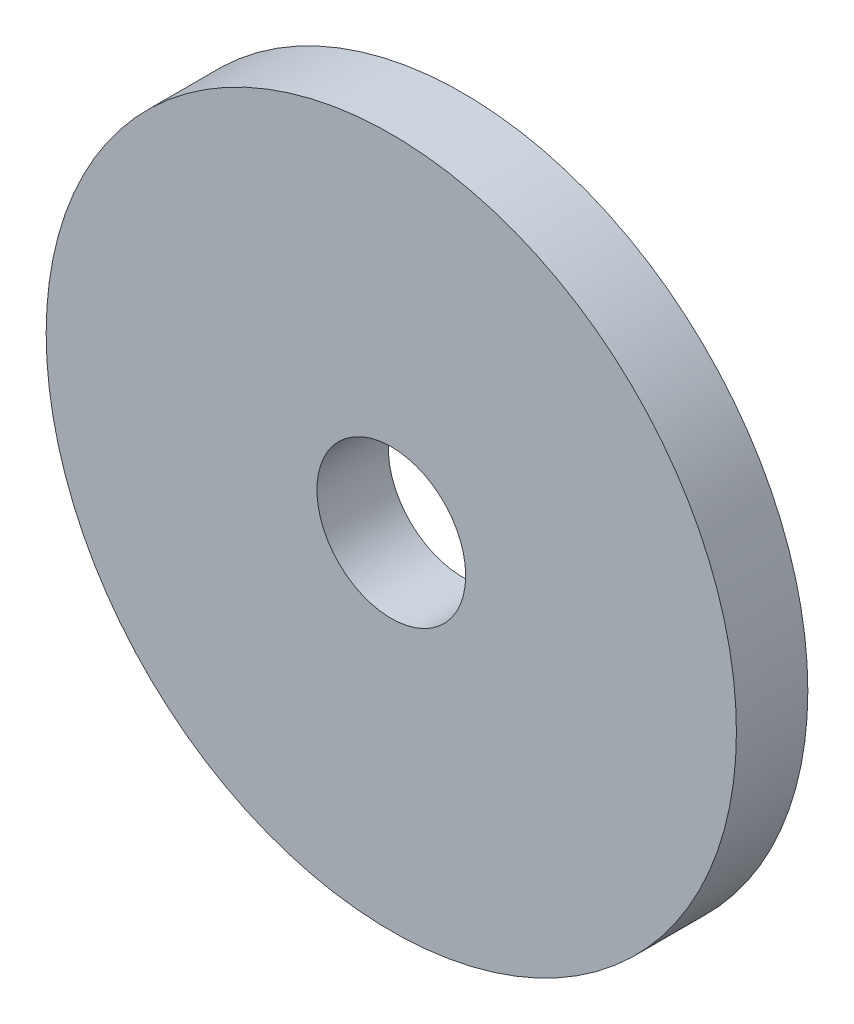
from build123d import *

# Parameters (mm, degrees)
SKETCH1_R           = 14.732
BOSS_EXTRUDE1_DEPTH = 3.048
SKETCH2_R           = 3.175
CUT_EXTRUDE1_DEPTH  = 3.048


with BuildPart() as part:
    # Sketch1 → Boss-Extrude1 (new body)
    with BuildSketch(Plane.XY):
        Circle(SKETCH1_R)
    extrude(amount=BOSS_EXTRUDE1_DEPTH)

    # Sketch2 → Cut-Extrude1 (cut)
    with BuildSketch(Plane.XY.offset(3.048)):
        Circle(SKETCH2_R)
    extrude(amount=-CUT_EXTRUDE1_DEPTH, mode=Mode.SUBTRACT)


solid = part.part
